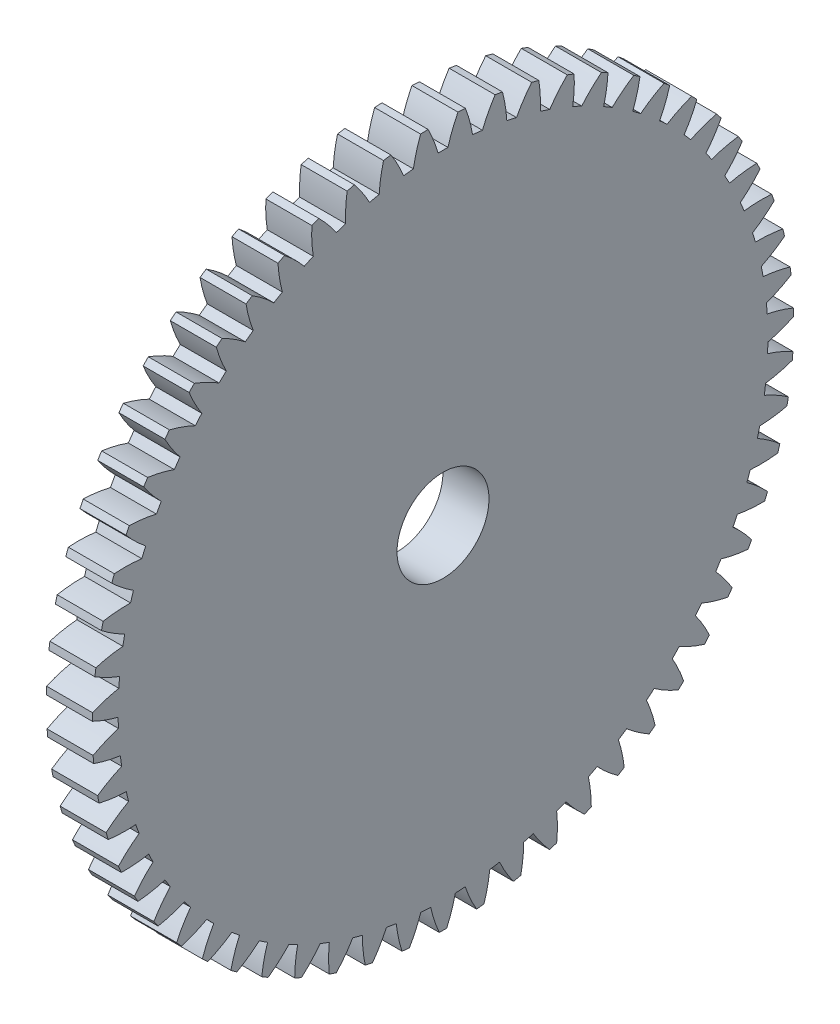
from build123d import *

# Parameters (mm, degrees)
BASPROSKE_W     = 4
BASPROSKE_H     = 30.5
TOOTHCUT_DEPTH  = 44.318587235
TEETHCUTS_COUNT = 59
TEETHCUTS_ANGLE = 353.898305085
BORSKE_R        = 4
BORE_DEPTH      = 50.0000508


with BuildPart() as part:
    # BasProSke → Base-Revolve (revolve)
    with BuildSketch(Plane(origin=(0, 0, 0), x_dir=(1, 0, 0), z_dir=(0, 1, 0)), mode=Mode.PRIVATE) as base_revolve_sk:
        with Locations((2, 15.25)):
            Rectangle(BASPROSKE_W, BASPROSKE_H)
    revolve(base_revolve_sk.sketch.rotate(Axis((-10, 0, 0), (1, 0, 0)), 180), axis=Axis((-10, 0, 0), (1, 0, 0)))

    # TooCutSke → ToothCut (cut, through all)
    with BuildSketch(Plane(origin=(0, 0, 0), x_dir=(0, 0, -1), z_dir=(1, 0, 0))):
        with BuildLine():
            ThreePointArc((0.430794105, 28.245715028), (0, 28.249), (-0.430794105, 28.245715028))
            ThreePointArc((-0.430794105, 28.245715028), (-0.814615912, 29.394097581), (-1.314100174, 30.49710127))
            ThreePointArc((-1.314100174, 30.49710127), (0, 30.5254), (1.314100174, 30.49710127))
            ThreePointArc((1.314100174, 30.49710127), (0.814615912, 29.394097581), (0.430794105, 28.245715028))
        make_face()
    toothcut = extrude(amount=TOOTHCUT_DEPTH, mode=Mode.SUBTRACT)

    # TeethCuts: ToothCut ×59 about axis
    teethcuts_axis = Axis((-10, 0, 0), (1, 0, 0))
    for i in range(1, TEETHCUTS_COUNT):
        add(toothcut.rotate(teethcuts_axis, i * TEETHCUTS_ANGLE / (TEETHCUTS_COUNT - 1)), mode=Mode.SUBTRACT)

    # BorSke → Bore (cut, symmetric)
    with BuildSketch(Plane(origin=(0, 0, 0), x_dir=(0, 0, -1), z_dir=(1, 0, 0))):
        with Locations(Location((0, 0, 0), (0, 0, 180))):
            Circle(BORSKE_R)
    extrude(amount=BORE_DEPTH, both=True, mode=Mode.SUBTRACT)


solid = part.part
